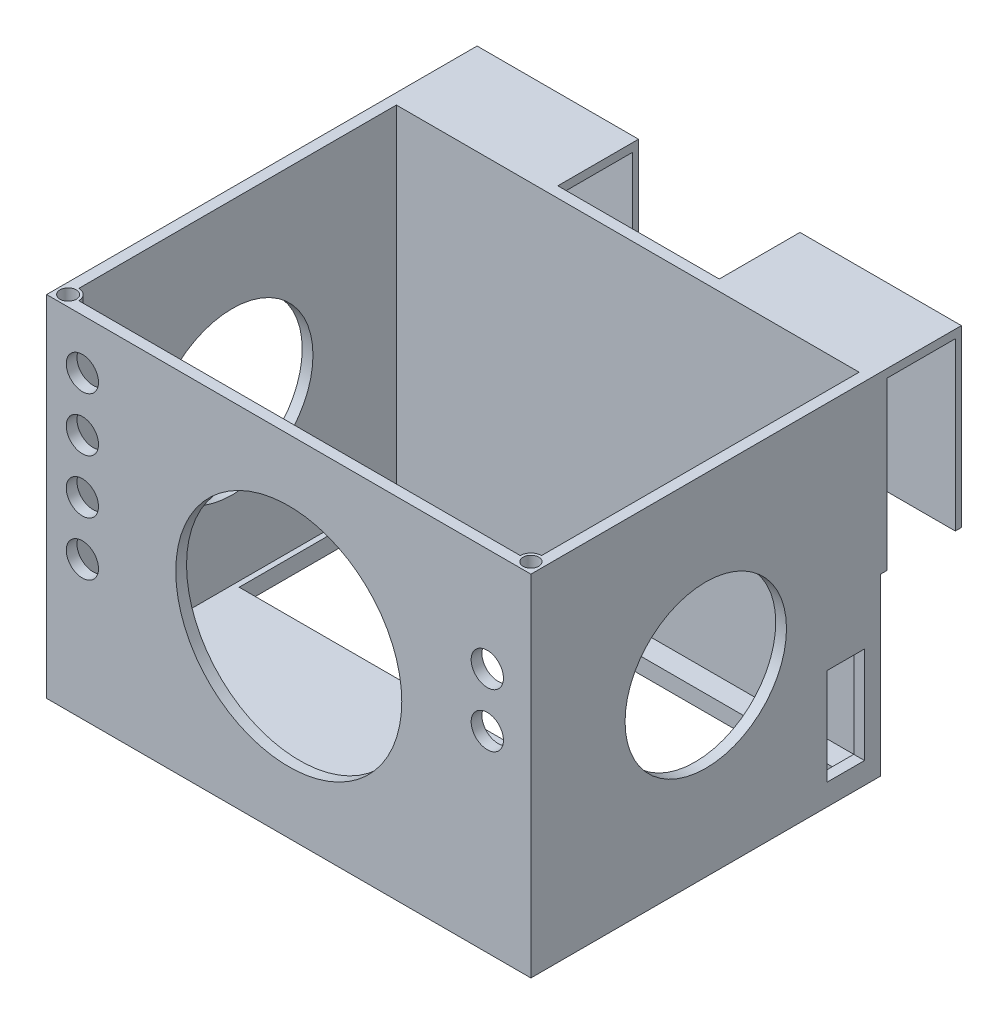
from build123d import *

# Parameters (mm, degrees)
SKETCH7_W           = 90
SKETCH7_H           = 65
BOSS_EXTRUDE2_DEPTH = 65
SKETCH10_W          = 86
SKETCH10_H          = 61
CUT_EXTRUDE2_DEPTH  = 62
SKETCH12_R          = 15
CUT_EXTRUDE3_DEPTH  = 91
SKETCH13_R          = 21
SKETCH13_R_2        = 3
CUT_EXTRUDE4_DEPTH  = 2
SKETCH14_W          = 7
SKETCH14_H          = 17.962946586
CUT_EXTRUDE5_DEPTH  = 5
SKETCH15_W          = 84
SKETCH15_H          = 26.21557427
CUT_EXTRUDE6_DEPTH  = 5
SKETCH17_W          = 30
SKETCH17_H          = 32.5
BOSS_EXTRUDE3_DEPTH = 15
SKETCH18_W          = 12.726486876
SKETCH18_H          = 30.948281703
CUT_EXTRUDE7_DEPTH  = 91
SKETCH20_W          = 24.28117476
SKETCH20_H          = 6.721130416
BOSS_EXTRUDE4_DEPTH = 10
SKETCH21_W          = 21.308601662
SKETCH21_H          = 6.528068718
CUT_EXTRUDE9_DEPTH  = 52.082060801
BOSS_EXTRUDE5_DEPTH = 5
SKETCH24_R          = 1.516132664
SKETCH24_R_2        = 1.46792115
CUT_EXTRUDE10_DEPTH = 3
SKETCH25_R          = 2.5
CUT_EXTRUDE11_DEPTH = 1


with BuildPart() as part:
    # Sketch7 → Boss-Extrude2 (new body)
    with BuildSketch(Plane(origin=(0, 0, 0), x_dir=(1, 0, 0), z_dir=(0, 1, 0))):
        Rectangle(SKETCH7_W, SKETCH7_H)
    extrude(amount=-BOSS_EXTRUDE2_DEPTH)

    # Sketch10 → Cut-Extrude2 (cut)
    with BuildSketch(Plane(origin=(0, 0, 0), x_dir=(1, 0, 0), z_dir=(0, 1, 0))):
        Rectangle(SKETCH10_W, SKETCH10_H)
    extrude(amount=-CUT_EXTRUDE2_DEPTH, mode=Mode.SUBTRACT)

    # Sketch12 → Cut-Extrude3 (cut, through all)
    with BuildSketch(Plane.ZY.offset(45)):
        with Locations((0, -32.5)):
            Circle(SKETCH12_R)
    extrude(amount=-CUT_EXTRUDE3_DEPTH, mode=Mode.SUBTRACT)

    # Sketch13 → Cut-Extrude4 (cut)
    with BuildSketch(Plane.XY.offset(32.5)):
        with Locations((0, -32.5)):
            Circle(SKETCH13_R)
        with Locations((-38.356194479, -9.309094371)):
            Circle(SKETCH13_R_2)
        with Locations((-38.356194479, -19.309094371)):
            Circle(SKETCH13_R_2)
        with Locations((-38.356194479, -29.309094371)):
            Circle(SKETCH13_R_2)
        with Locations((-38.356194479, -39.309094371)):
            Circle(SKETCH13_R_2)
        with Locations((36.896991428, -19.309094371)):
            Circle(SKETCH13_R_2)
        with Locations((36.896991428, -29.309094371)):
            Circle(SKETCH13_R_2)
    extrude(amount=-CUT_EXTRUDE4_DEPTH, mode=Mode.SUBTRACT)

    # Sketch14 → Cut-Extrude5 (cut)
    with BuildSketch(Plane(origin=(45, 0, 0), x_dir=(0, 0, -1), z_dir=(1, 0, 0))):
        with Locations((26, -52.018526707)):
            Rectangle(SKETCH14_W, SKETCH14_H)
    extrude(amount=-CUT_EXTRUDE5_DEPTH, mode=Mode.SUBTRACT)

    # Sketch15 → Cut-Extrude6 (cut)
    with BuildSketch(Plane.XZ.offset(65)):
        with Locations((0, -13.392212865)):
            Rectangle(SKETCH15_W, SKETCH15_H)
    extrude(amount=-CUT_EXTRUDE6_DEPTH, mode=Mode.SUBTRACT)

    # Sketch17 → Boss-Extrude3 (add)
    with BuildSketch(Plane(origin=(0, 0, -32.5), x_dir=(-1, 0, 0), z_dir=(0, 0, -1))):
        with Locations((-30, -16.25)):
            Rectangle(SKETCH17_W, SKETCH17_H)
        with Locations((30, -16.25)):
            Rectangle(SKETCH17_W, SKETCH17_H)
    extrude(amount=BOSS_EXTRUDE3_DEPTH)

    # Sketch18 → Cut-Extrude7 (cut, through all)
    with BuildSketch(Plane(origin=(45, 0, 0), x_dir=(0, 0, -1), z_dir=(1, 0, 0))):
        with Locations((40.003797932, -17.025859149)):
            Rectangle(SKETCH18_W, SKETCH18_H)
    extrude(amount=-CUT_EXTRUDE7_DEPTH, mode=Mode.SUBTRACT)

    # Sketch20 → Boss-Extrude4 (add)
    with BuildSketch(Plane(origin=(0, 0, -32.5), x_dir=(-1, 0, 0), z_dir=(0, 0, -1))):
        with Locations((0, -57.278504407)):
            Rectangle(SKETCH20_W, SKETCH20_H)
        with Locations((0, -17.278504407)):
            Rectangle(SKETCH20_W, SKETCH20_H)
    extrude(amount=BOSS_EXTRUDE4_DEPTH)

    # Sketch21 → Cut-Extrude9 (cut, through all)
    with BuildSketch(Plane(origin=(0, -13.917939199, 0), x_dir=(1, 0, 0), z_dir=(0, 1, 0))):
        with Locations((-0.070940944, 37.501061987)):
            Rectangle(SKETCH21_W, SKETCH21_H)
    extrude(amount=-CUT_EXTRUDE9_DEPTH, mode=Mode.SUBTRACT)

    # Sketch23 → Boss-Extrude5 (add)
    with BuildSketch(Plane(origin=(0, 0, 0), x_dir=(1, 0, 0), z_dir=(0, 1, 0))):
        with BuildLine():
            Line((43, -28.521055724), (43, -30.5))
            Line((43, -30.5), (41.021055724, -30.5))
            ThreePointArc((41.021055724, -30.5), (41.600675083, -29.100675083), (43, -28.521055724))
        make_face()
        with BuildLine():
            Line((-43, -28.521055724), (-43, -30.5))
            Line((-43, -30.5), (-41.021055724, -30.5))
            ThreePointArc((-41.021055724, -30.5), (-41.600675083, -29.100675083), (-43, -28.521055724))
        make_face()
    extrude(amount=-BOSS_EXTRUDE5_DEPTH)

    # Sketch24 → Cut-Extrude10 (cut)
    with BuildSketch(Plane(origin=(0, 0, 0), x_dir=(1, 0, 0), z_dir=(0, 1, 0))):
        with Locations((-43, -30.5)):
            Circle(SKETCH24_R)
        with Locations((43, -30.5)):
            Circle(SKETCH24_R_2)
    extrude(amount=-CUT_EXTRUDE10_DEPTH, mode=Mode.SUBTRACT)

    # Sketch25 → Cut-Extrude11 (cut)
    with BuildSketch(Plane.XZ.offset(65)):
        with Locations((0, -28.5)):
            Circle(SKETCH25_R)
    extrude(amount=-CUT_EXTRUDE11_DEPTH, mode=Mode.SUBTRACT)


solid = part.part
